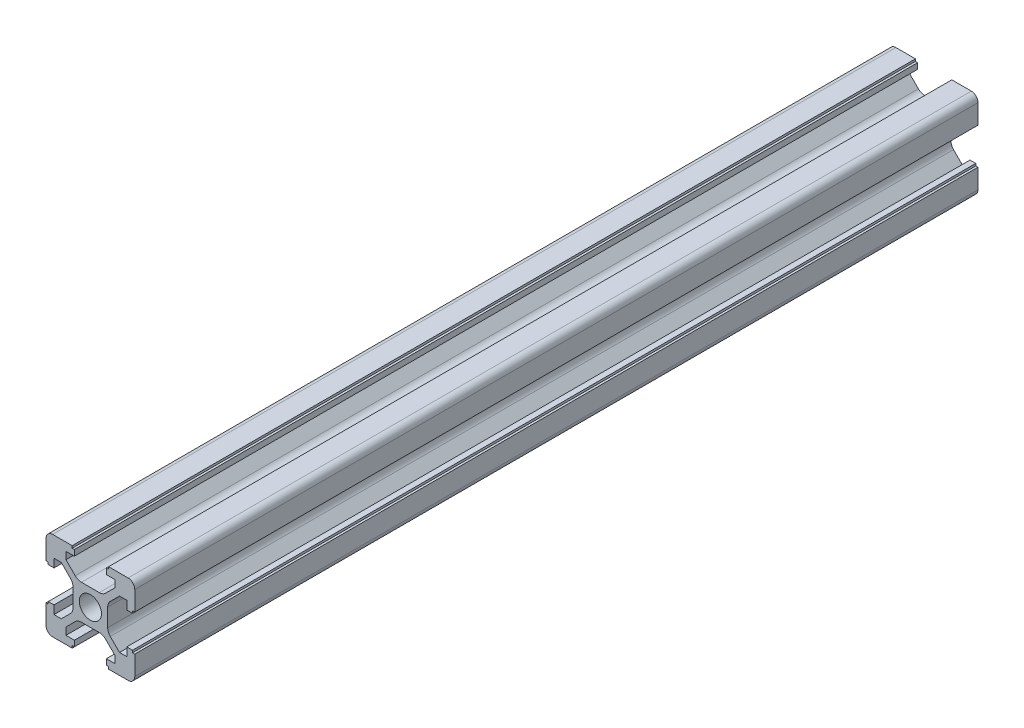
from build123d import *

# Parameters (mm, degrees)
SKETCH1_R           = 2.5
BOSS_EXTRUDE2_DEPTH = 190


with BuildPart() as part:
    # Sketch1 → Boss-Extrude2 (new body)
    with BuildSketch(Plane.XY):
        with BuildLine():
            Line((10, -4.1), (10, -8.5))
            ThreePointArc((10, -8.5), (9.560660172, -9.560660172), (8.5, -10))
            Line((8.5, -10), (4.1, -10))
            Line((4.1, -10), (4.1, -9.5))
            Line((4.1, -9.5), (3.6, -9.5))
            Line((3.6, -9.5), (3.6, -8.2))
            Line((3.6, -8.2), (5.5, -8.2))
            Line((5.5, -8.2), (5.5, -6.560660172))
            Line((5.5, -6.560660172), (3.425126266, -4.485786438))
            ThreePointArc((3.425126266, -4.485786438), (2.776279568, -4.052240935), (2.010912703, -3.9))
            Line((2.010912703, -3.9), (-2.010912703, -3.9))
            ThreePointArc((-2.010912703, -3.9), (-2.776279568, -4.052240935), (-3.425126266, -4.485786438))
            Line((-3.425126266, -4.485786438), (-5.5, -6.560660172))
            Line((-5.5, -6.560660172), (-5.5, -8.2))
            Line((-5.5, -8.2), (-3.6, -8.2))
            Line((-3.6, -8.2), (-3.6, -9.5))
            Line((-3.6, -9.5), (-4.1, -9.5))
            Line((-4.1, -9.5), (-4.1, -10))
            Line((-4.1, -10), (-8.5, -10))
            ThreePointArc((-8.5, -10), (-9.560660172, -9.560660172), (-10, -8.5))
            Line((-10, -8.5), (-10, -4.1))
            Line((-10, -4.1), (-9.5, -4.1))
            Line((-9.5, -4.1), (-9.5, -3.6))
            Line((-9.5, -3.6), (-8.2, -3.6))
            Line((-8.2, -3.6), (-8.2, -5.5))
            Line((-8.2, -5.5), (-6.560660172, -5.5))
            Line((-6.560660172, -5.5), (-4.485786438, -3.425126266))
            ThreePointArc((-4.485786438, -3.425126266), (-4.052240935, -2.776279568), (-3.9, -2.010912703))
            Line((-3.9, -2.010912703), (-3.9, 2.010912703))
            ThreePointArc((-3.9, 2.010912703), (-4.052240935, 2.776279568), (-4.485786438, 3.425126266))
            Line((-4.485786438, 3.425126266), (-6.560660172, 5.5))
            Line((-6.560660172, 5.5), (-8.2, 5.5))
            Line((-8.2, 5.5), (-8.2, 3.6))
            Line((-8.2, 3.6), (-9.5, 3.6))
            Line((-9.5, 3.6), (-9.5, 4.1))
            Line((-9.5, 4.1), (-10, 4.1))
            Line((-10, 4.1), (-10, 8.5))
            ThreePointArc((-10, 8.5), (-9.560660172, 9.560660172), (-8.5, 10))
            Line((-8.5, 10), (-4.1, 10))
            Line((-4.1, 10), (-4.1, 9.5))
            Line((-4.1, 9.5), (-3.6, 9.5))
            Line((-3.6, 9.5), (-3.6, 8.2))
            Line((-3.6, 8.2), (-5.5, 8.2))
            Line((-5.5, 8.2), (-5.5, 6.560660172))
            Line((-5.5, 6.560660172), (-3.425126266, 4.485786438))
            ThreePointArc((-3.425126266, 4.485786438), (-2.776279568, 4.052240935), (-2.010912703, 3.9))
            Line((-2.010912703, 3.9), (2.010912703, 3.9))
            ThreePointArc((2.010912703, 3.9), (2.776279568, 4.052240935), (3.425126266, 4.485786438))
            Line((3.425126266, 4.485786438), (5.5, 6.560660172))
            Line((5.5, 6.560660172), (5.5, 8.2))
            Line((5.5, 8.2), (3.6, 8.2))
            Line((3.6, 8.2), (3.6, 9.5))
            Line((3.6, 9.5), (4.1, 9.5))
            Line((4.1, 9.5), (4.1, 10))
            Line((4.1, 10), (8.5, 10))
            ThreePointArc((8.5, 10), (9.560660172, 9.560660172), (10, 8.5))
            Line((10, 8.5), (10, 4.1))
            Line((10, 4.1), (9.5, 4.1))
            Line((9.5, 4.1), (9.5, 3.6))
            Line((9.5, 3.6), (8.2, 3.6))
            Line((8.2, 3.6), (8.2, 5.5))
            Line((8.2, 5.5), (6.560660172, 5.5))
            Line((6.560660172, 5.5), (4.485786438, 3.425126266))
            ThreePointArc((4.485786438, 3.425126266), (4.052240935, 2.776279568), (3.9, 2.010912703))
            Line((3.9, 2.010912703), (3.9, -2.010912703))
            ThreePointArc((3.9, -2.010912703), (4.052240935, -2.776279568), (4.485786438, -3.425126266))
            Line((4.485786438, -3.425126266), (6.560660172, -5.5))
            Line((6.560660172, -5.5), (8.2, -5.5))
            Line((8.2, -5.5), (8.2, -3.6))
            Line((8.2, -3.6), (9.5, -3.6))
            Line((9.5, -3.6), (9.5, -4.1))
            Line((9.5, -4.1), (10, -4.1))
        make_face()
        Circle(SKETCH1_R, mode=Mode.SUBTRACT)
    extrude(amount=BOSS_EXTRUDE2_DEPTH)


solid = part.part
